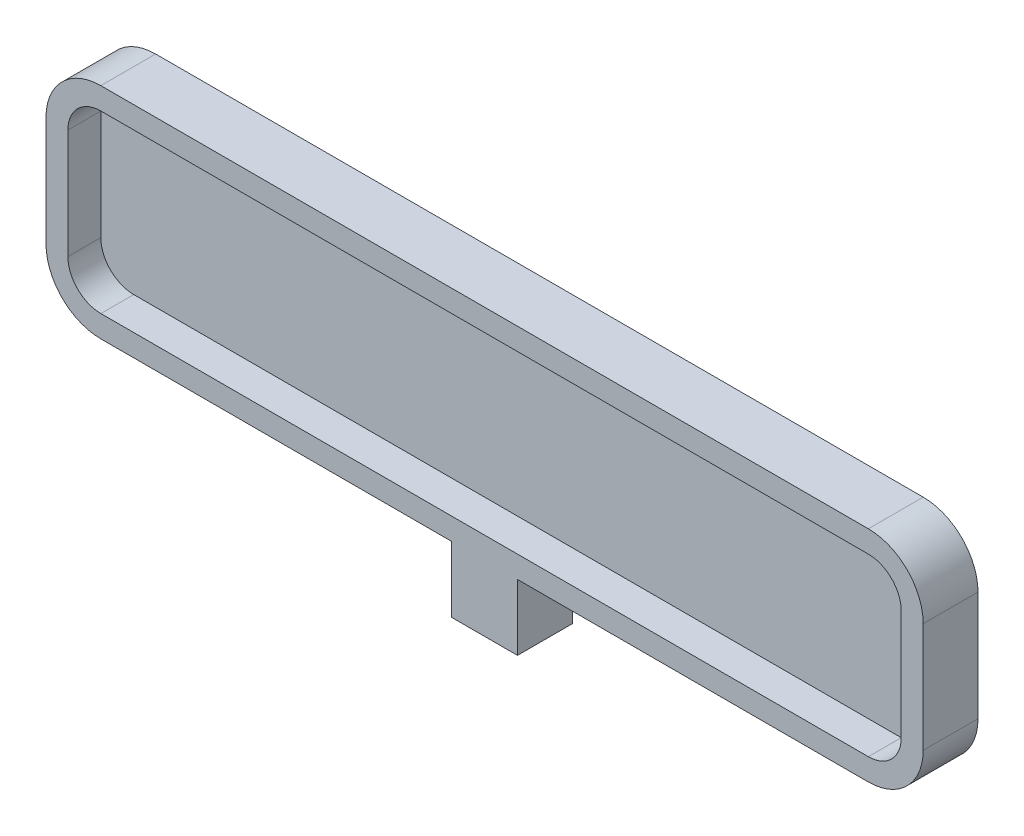
from build123d import *

# Parameters (mm, degrees)
SKETCH2_W           = 80
SKETCH2_H           = 20
BOSS_EXTRUDE1_DEPTH = 5
FILLET1_R           = 5
SHELL1_T            = -2
SKETCH3_W           = 6
SKETCH3_H           = 5
BOSS_EXTRUDE2_DEPTH = 6
SKETCH4_R           = 1.425
CUT_EXTRUDE1_DEPTH  = 4


with BuildPart() as part:
    # Sketch2 → Boss-Extrude1 (new body)
    with BuildSketch(Plane.XY):
        Rectangle(SKETCH2_W, SKETCH2_H)
    extrude(amount=BOSS_EXTRUDE1_DEPTH)

    # Fillet1
    fillet1_edges = [part.edges().sort_by_distance(p)[0] for p in [
        (-40, 10, 2.5),
        (40, 10, 2.5),
        (40, -10, 2.5),
        (-40, -10, 2.5),
    ]]
    fillet(fillet1_edges, radius=FILLET1_R)

    # Shell1
    shell1_openings = [part.faces().sort_by_distance(p)[0] for p in [
        (0, 0, 5),
    ]]
    offset(amount=SHELL1_T, openings=shell1_openings, kind=Kind.INTERSECTION)

    # Sketch3 → Boss-Extrude2 (add)
    with BuildSketch(Plane.XZ.offset(10)):
        with Locations((0, 2.5)):
            Rectangle(SKETCH3_W, SKETCH3_H)
    extrude(amount=BOSS_EXTRUDE2_DEPTH)

    # Sketch4 → Cut-Extrude1 (cut)
    with BuildSketch(Plane.XZ.offset(16)):
        with Locations((0, 2.5)):
            Circle(SKETCH4_R)
    extrude(amount=-CUT_EXTRUDE1_DEPTH, mode=Mode.SUBTRACT)


solid = part.part
